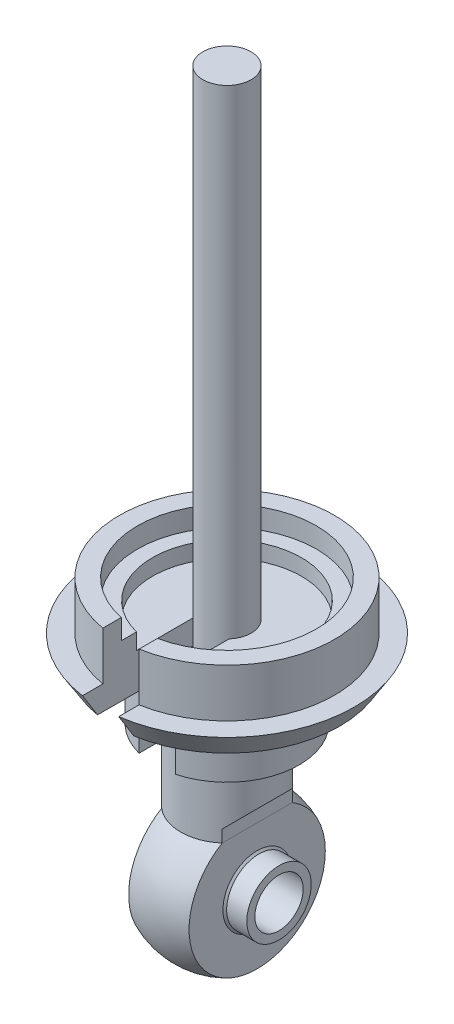
from build123d import *

# Parameters (mm, degrees)
CUT_EXTRUDE1_DEPTH      = 5
CUT_EXTRUDE2_DEPTH      = 3
CUT_EXTRUDE2_DEPTH_BACK = 1.51
CUT_EXTRUDE3_DEPTH      = 6


with BuildPart() as part:
    # Sketch2 → Revolve1 (revolve)
    with BuildSketch(Plane(origin=(0, 0, 0), x_dir=(0, 0, -1), z_dir=(1, 0, 0))):
        Polygon((0, -0.625), (1.5, -0.625), (1.5, -30.625), (2.875, -30.625), (2.875, -40.377156), (0, -40.377156), align=None)
    revolve(axis=Axis((0, -44, 0), (0, 1, 0)))

    # Sketch4 → Cut-Extrude1 (cut, symmetric)
    with BuildSketch(Plane.XY):
        Polygon((1.875, -47.625716), (1.875, -39.625), (2.875, -38.625), (2.875, -47.625716), align=None)
        Polygon((-1.875, -39.625), (-2.875, -38.625), (-2.875, -47.625716), (-1.875, -47.625716), align=None)
    extrude(amount=CUT_EXTRUDE1_DEPTH, both=True, mode=Mode.SUBTRACT)

    # Sketch5 → Revolve3 (revolve)
    with BuildSketch(Plane(origin=(0, 0, 0), x_dir=(0, 0, -1), z_dir=(1, 0, 0))):
        Polygon((4.625, -30.374201), (1.5, -30.374201), (1.5, -31.757852), (2.95, -31.757852), (2.95, -35.974201), (4.475, -35.974201), (4.475, -32.624201), (7, -32.624201), (7.925, -31.124201), (6.675, -31.124201), (6.675, -28.124201), (5.55, -28.124201), (5.55, -29.374201), (4.625, -29.374201), align=None)
    revolve(axis=Axis((0, -44, 0), (0, 1, 0)))

    # Sketch6 → Cut-Extrude2 (cut, two sides)
    with BuildSketch(Plane(origin=(0, -30.374201, 0), x_dir=(1, 0, 0), z_dir=(0, 1, 0))) as cut_extrude2_sk:
        with BuildLine():
            Line((-1.125, -0.992157), (-1.125, -8.743655))
            Line((-1.125, -8.743655), (1.125, -8.743655))
            Line((1.125, -8.743655), (1.125, -0.992157))
            ThreePointArc((1.125, -0.992157), (0, -1.5), (-1.125, -0.992157))
        make_face()
    extrude(amount=CUT_EXTRUDE2_DEPTH, mode=Mode.SUBTRACT)
    extrude(cut_extrude2_sk.sketch, amount=-CUT_EXTRUDE2_DEPTH_BACK, mode=Mode.SUBTRACT)

    # Sketch7 → Cut-Extrude3 (cut)
    with BuildSketch(Plane(origin=(0, -31.884201, 0), x_dir=(1, 0, 0), z_dir=(0, 1, 0))):
        with BuildLine():
            Line((-1.125, -4.331282), (-1.125, -2.727063))
            ThreePointArc((-1.125, -2.727063), (0, -2.95), (1.125, -2.727063))
            Line((1.125, -2.727063), (1.125, -4.331282))
            Line((1.125, -4.331282), (1.125, -8.743655))
            Line((1.125, -8.743655), (-1.125, -8.743655))
            Line((-1.125, -8.743655), (-1.125, -4.331282))
        make_face()
    extrude(amount=-CUT_EXTRUDE3_DEPTH, mode=Mode.SUBTRACT)


with BuildPart() as body_2:
    # Sketch3 → Spherical Bearing (revolve)
    with BuildSketch(Plane.XY):
        Polygon((3.23, -42.5), (0, -42.5), (-3.23, -42.5), (-3.23, -42), (0, -42), (3.23, -42), align=None)
        with BuildLine():
            ThreePointArc((-1.875, -41.872708), (-1.928551, -41.935488), (-1.98, -42))
            Line((-1.98, -42), (0, -42))
            Line((0, -42), (1.98, -42))
            ThreePointArc((1.98, -42), (1.928551, -41.935488), (1.875, -41.872708))
            ThreePointArc((1.875, -41.872708), (0, -41.026303), (-1.875, -41.872708))
        make_face()
        with BuildLine():
            Line((-1.875, -39.772116), (-1.875, -41.872708))
            ThreePointArc((-1.875, -41.872708), (0, -41.026303), (1.875, -41.872708))
            Line((1.875, -41.872708), (1.875, -39.772116))
            ThreePointArc((1.875, -39.772116), (0, -39.375), (-1.875, -39.772116))
        make_face()
    revolve(axis=Axis((9.866349, -44, 0), (-1, 0, 0)))


solid = Compound([part.part, body_2.part])
